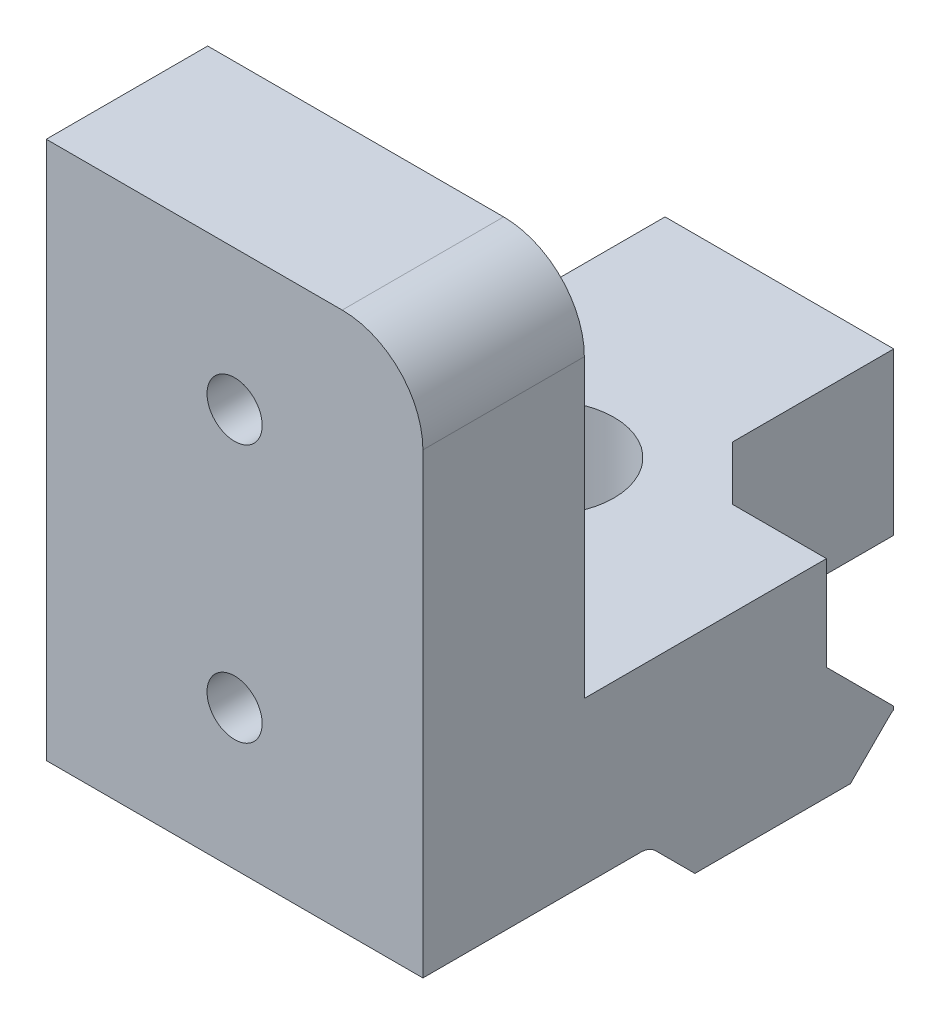
from build123d import *

# Parameters (mm, degrees)
SKETCH1_W                = 20
SKETCH1_H                = 6
BOSS_EXTRUDE1_DEPTH      = 14
CUT_EXTRUDE1_REACH       = 9.69
SKETCH2_R                = 2.6
SKETCH3_W                = 14
SKETCH3_H                = 20
BOSS_EXTRUDE2_DEPTH      = 3
BOSS_EXTRUDE2_DEPTH_BACK = 3
SKETCH4_R                = 1.025
CUT_EXTRUDE4_DEPTH       = 6
SKETCH5_W                = 5.5
SKETCH5_H                = 8
CUT_EXTRUDE5_DEPTH       = 6
CHAMFER1_SIZE            = 2
CHAMFER2_SIZE            = 2.5
SKETCH6_W                = 5.5
SKETCH6_H                = 0.407228715
CUT_EXTRUDE6_DEPTH       = 2.69
FILLET1_R                = 3


with BuildPart() as part:
    # Sketch1 → Boss-Extrude1 (new body)
    with BuildSketch(Plane(origin=(32.364284334, 0, 0), x_dir=(0, 0, -1), z_dir=(1, 0, 0))):
        with Locations((-7.875866483, 38.765059464)):
            Rectangle(SKETCH1_W, SKETCH1_H)
        with BuildLine():
            Line((-12.22448084, 35.533673821), (-10.765866483, 34.075059464))
            Line((-10.765866483, 34.075059464), (-4.985866483, 34.075059464))
            Line((-4.985866483, 34.075059464), (-3.527252126, 35.533673821))
            ThreePointArc((-3.527252126, 35.533673821), (-3.27095768, 35.704924294), (-2.968637768, 35.765059464))
            Line((-2.968637768, 35.765059464), (-12.783095197, 35.765059464))
            ThreePointArc((-12.783095197, 35.765059464), (-12.480775285, 35.704924294), (-12.22448084, 35.533673821))
        make_face()
    extrude(amount=BOSS_EXTRUDE1_DEPTH)

    # Sketch2 → Cut-Extrude1 (cut, up to next)
    with BuildSketch(Plane.XZ.offset(-34.075059464), mode=Mode.PRIVATE) as cut_extrude1_sk1:
        with Locations((37.864284334, 7.875866483)):
            Circle(SKETCH2_R)
    cut_extrude1_tool1 = extrude(cut_extrude1_sk1.sketch, amount=-CUT_EXTRUDE1_REACH, mode=Mode.PRIVATE) & part.part
    add(cut_extrude1_tool1.solids().sort_by_distance((37.864284, 34.075059, 7.875866))[0], mode=Mode.SUBTRACT)

    # Sketch3 → Boss-Extrude2 (add, two sides)
    with BuildSketch(Plane.XY.offset(17.875866483)) as boss_extrude2_sk:
        with Locations((39.364284334, 45.765059464)):
            Rectangle(SKETCH3_W, SKETCH3_H)
    extrude(amount=BOSS_EXTRUDE2_DEPTH)
    extrude(boss_extrude2_sk.sketch, amount=-BOSS_EXTRUDE2_DEPTH_BACK)

    # Sketch4 → Cut-Extrude4 (cut)
    with BuildSketch(Plane.XY.offset(20.875866483)):
        with Locations((39.364284334, 50.565059464)):
            Circle(SKETCH4_R)
        with Locations((39.364284334, 40.965059464)):
            Circle(SKETCH4_R)
    extrude(amount=-CUT_EXTRUDE4_DEPTH, mode=Mode.SUBTRACT)

    # Sketch5 → Cut-Extrude5 (cut)
    with BuildSketch(Plane(origin=(0, 41.765059464, 0), x_dir=(1, 0, 0), z_dir=(0, 1, 0))):
        with Locations((43.614284334, -1.875866483)):
            Rectangle(SKETCH5_W, SKETCH5_H)
    extrude(amount=-CUT_EXTRUDE5_DEPTH, mode=Mode.SUBTRACT)

    # Chamfer1
    chamfer1_edges = [part.edges().sort_by_distance(p)[0] for p in [
        (40.864284334, 38.765059464, 5.875866483),
    ]]
    chamfer(chamfer1_edges, length=CHAMFER1_SIZE)

    # Chamfer2
    chamfer2_edges = [part.edges().sort_by_distance(p)[0] for p in [
        (44.614284334, 35.765059464, 5.875866483),
    ]]
    chamfer(chamfer2_edges, length=CHAMFER2_SIZE)

    # Sketch6 → Cut-Extrude6 (cut, through all)
    with BuildSketch(Plane(origin=(0, 35.765059464, 0), x_dir=(1, 0, 0), z_dir=(0, 1, 0))):
        with Locations((43.614284334, -3.172252126)):
            Rectangle(SKETCH6_W, SKETCH6_H)
    extrude(amount=-CUT_EXTRUDE6_DEPTH, mode=Mode.SUBTRACT)

    # Fillet1
    fillet1_edges = [part.edges().sort_by_distance(p)[0] for p in [
        (46.364284334, 55.765059464, 17.875866483),
    ]]
    fillet(fillet1_edges, radius=FILLET1_R)


solid = part.part
